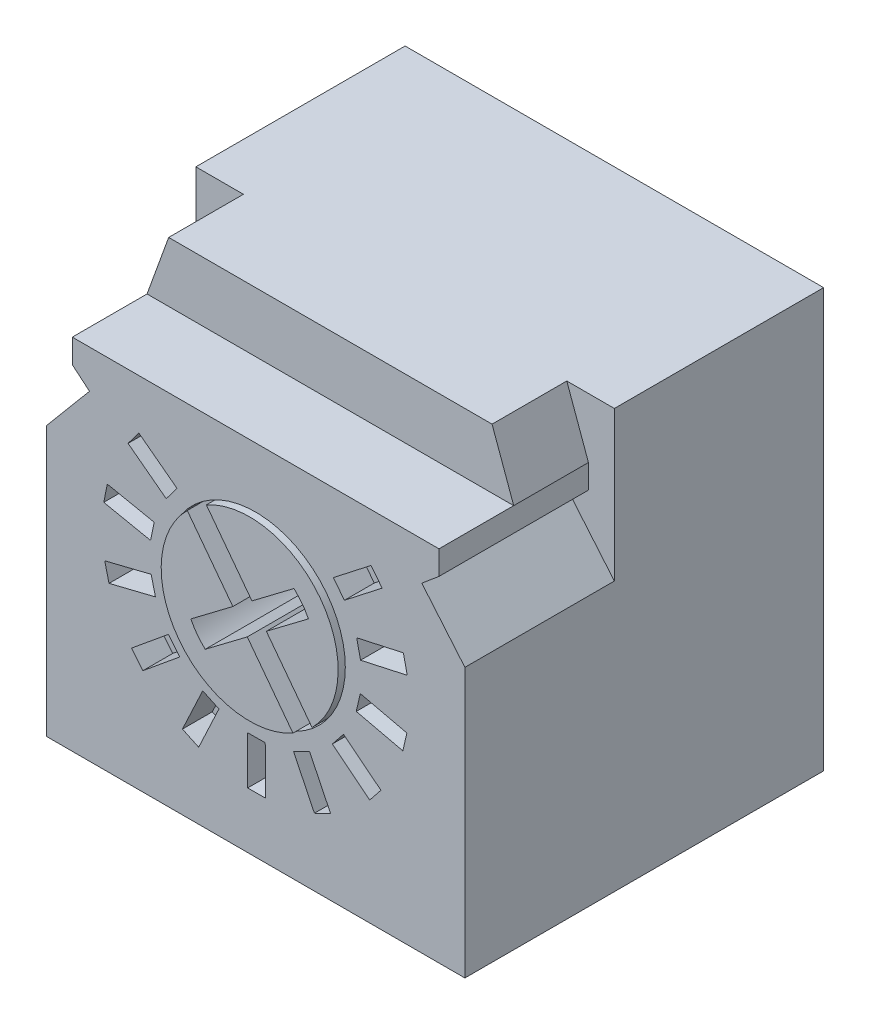
from build123d import *

# Parameters (mm, degrees)
BASE_EXTRUDE_START  = -6
SKETCH1_W           = 7
SKETCH1_H           = 7
BASE_EXTRUDE_DEPTH  = 6
SKETCH2_R           = 1.5
CUT_EXTRUDE1_DEPTH  = 3
SKETCH3_R           = 1.48
BOSS_EXTRUDE1_DEPTH = 3.1
CUT_EXTRUDE2_DEPTH  = 2
CUT_EXTRUDE3_DEPTH  = 0.5
CUT_EXTRUDE4_DEPTH  = 2.5
BOSS_EXTRUDE2_DEPTH = 1.25


with BuildPart() as part:
    # Sketch1 → Base-Extrude (new body)
    with BuildSketch(Plane.XY.offset(BASE_EXTRUDE_START)):
        Rectangle(SKETCH1_W, SKETCH1_H)
    extrude(amount=BASE_EXTRUDE_DEPTH)

    # Sketch2 → Cut-Extrude1 (cut)
    with BuildSketch(Plane.XY):
        Circle(SKETCH2_R)
    extrude(amount=-CUT_EXTRUDE1_DEPTH, mode=Mode.SUBTRACT)

    # Sketch3 → Boss-Extrude1 (add)
    with BuildSketch(Plane.XY.offset(-3)):
        Circle(SKETCH3_R)
    extrude(amount=BOSS_EXTRUDE1_DEPTH)

    # Sketch4 → Cut-Extrude2 (cut)
    with BuildSketch(Plane.XY.offset(0.1)):
        with BuildLine():
            Line((0.724096874, -1.290768654), (-0.039924426, -0.279012083))
            Line((-0.039924426, -0.279012083), (-0.743721804, -0.81048003))
            ThreePointArc((-0.743721804, -0.81048003), (-0.87868568, -0.661748801), (-0.984357933, -0.490957696))
            Line((-0.984357933, -0.490957696), (-0.280973901, 0.040198115))
            Line((-0.280973901, 0.040198115), (-1.043307072, 1.049719178))
            ThreePointArc((-1.043307072, 1.049719178), (-0.891883058, 1.181077733), (-0.724096874, 1.290768654))
            Line((-0.724096874, 1.290768654), (0.038236297, 0.28124759))
            Line((0.038236297, 0.28124759), (0.741620329, 0.812403402))
            ThreePointArc((0.741620329, 0.812403402), (0.876968937, 0.664022201), (0.98308315, 0.493505339))
            Line((0.98308315, 0.493505339), (0.279285772, -0.037962608))
            Line((0.279285772, -0.037962608), (1.043307072, -1.049719178))
            ThreePointArc((1.043307072, -1.049719178), (0.891883058, -1.181077733), (0.724096874, -1.290768654))
        make_face()
    extrude(amount=-CUT_EXTRUDE2_DEPTH, mode=Mode.SUBTRACT)

    # Sketch5 → Cut-Extrude3 (cut)
    with BuildSketch(Plane.XY):
        Polygon((1.3, 1.2), (1.931123884, 1.691612289), (2.115478493, 1.454940832), (1.484354608, 0.963328543), align=None)
        Polygon((1.689974186, 0.523437915), (2.471261862, 0.695454097), (2.53576793, 0.402471219), (1.754480254, 0.230455037), align=None)
        Polygon((1.750691662, -0.255105281), (2.529925297, -0.436199021), (2.462015144, -0.728411634), (1.68278151, -0.547317894), align=None)
        Polygon((1.470322877, -0.98394646), (2.095684825, -1.482867731), (1.908589348, -1.717378462), (1.283227401, -1.21845719), align=None)
        Polygon((0.903491923, -1.52108591), (1.25314327, -2.240630165), (0.983314174, -2.371749421), (0.633662827, -1.652205165), align=None)
        Polygon((0.160634151, -1.761873057), (0.166452524, -2.561851898), (-0.133539541, -2.564033789), (-0.139357915, -1.764054947), align=None)
        Polygon((-0.613519882, -1.659395479), (-0.952668072, -2.383949483), (-1.224375823, -2.256768912), (-0.885227633, -1.532214907), align=None)
        Polygon((-1.268142184, -1.233618823), (-1.886180889, -1.741583546), (-2.07666766, -1.509819032), (-1.458628956, -1.001854309), align=None)
        Polygon((-1.675693067, -0.567496913), (-2.452210156, -0.759905877), (-2.524363518, -0.468711968), (-1.747846428, -0.276303004), align=None)
        Polygon((-1.756769622, 0.209190097), (-2.540476714, 0.369823822), (-2.480239067, 0.663713982), (-1.696531975, 0.503080257), align=None)
        Polygon((-1.49557575, 0.94512072), (-2.133783638, 1.427500956), (-1.952891049, 1.666828914), (-1.314683162, 1.184448678), align=None)
    extrude(amount=-CUT_EXTRUDE3_DEPTH, mode=Mode.SUBTRACT)

    # Sketch7 → Cut-Extrude4 (cut)
    with BuildSketch(Plane.XY):
        Polygon((3.5, 3.5), (-3.5, 3.5), (-3.5, 1), (-2.779166508, 1.859055904), (-3.066312501, 2.1), (-3.066312501, 2.5), (3.066312501, 2.5), (3.066312501, 2.1), (2.779166508, 1.859055904), (3.5, 1), align=None)
    extrude(amount=-CUT_EXTRUDE4_DEPTH, mode=Mode.SUBTRACT)

    # Sketch8 → Boss-Extrude2 (add)
    with BuildSketch(Plane.XY.offset(-2.5)):
        Polygon((-3.066312501, 2.5), (3.066312501, 2.5), (2.70444426, 3.5), (-2.70444426, 3.5), align=None)
    extrude(amount=BOSS_EXTRUDE2_DEPTH)


solid = part.part
